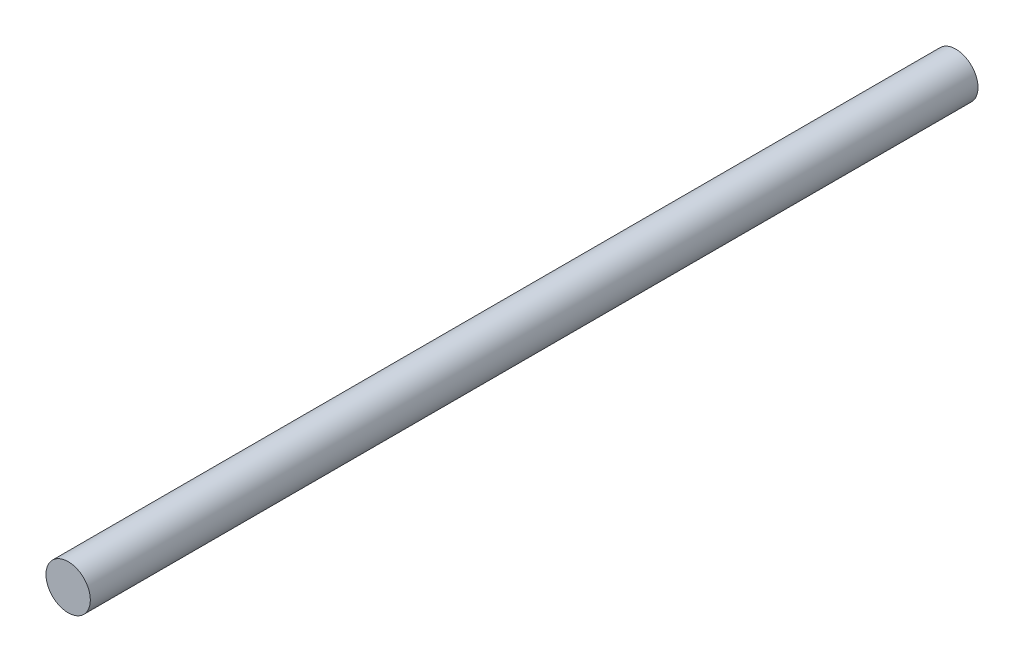
from build123d import *

# Parameters (mm, degrees)
CROQUIS1_R              = 1.5
SALIENTE_EXTRUIR1_DEPTH = 60


with BuildPart() as part:
    # Croquis1 → Saliente-Extruir1 (new body)
    with BuildSketch(Plane.XY):
        Circle(CROQUIS1_R)
    extrude(amount=SALIENTE_EXTRUIR1_DEPTH)


solid = part.part
